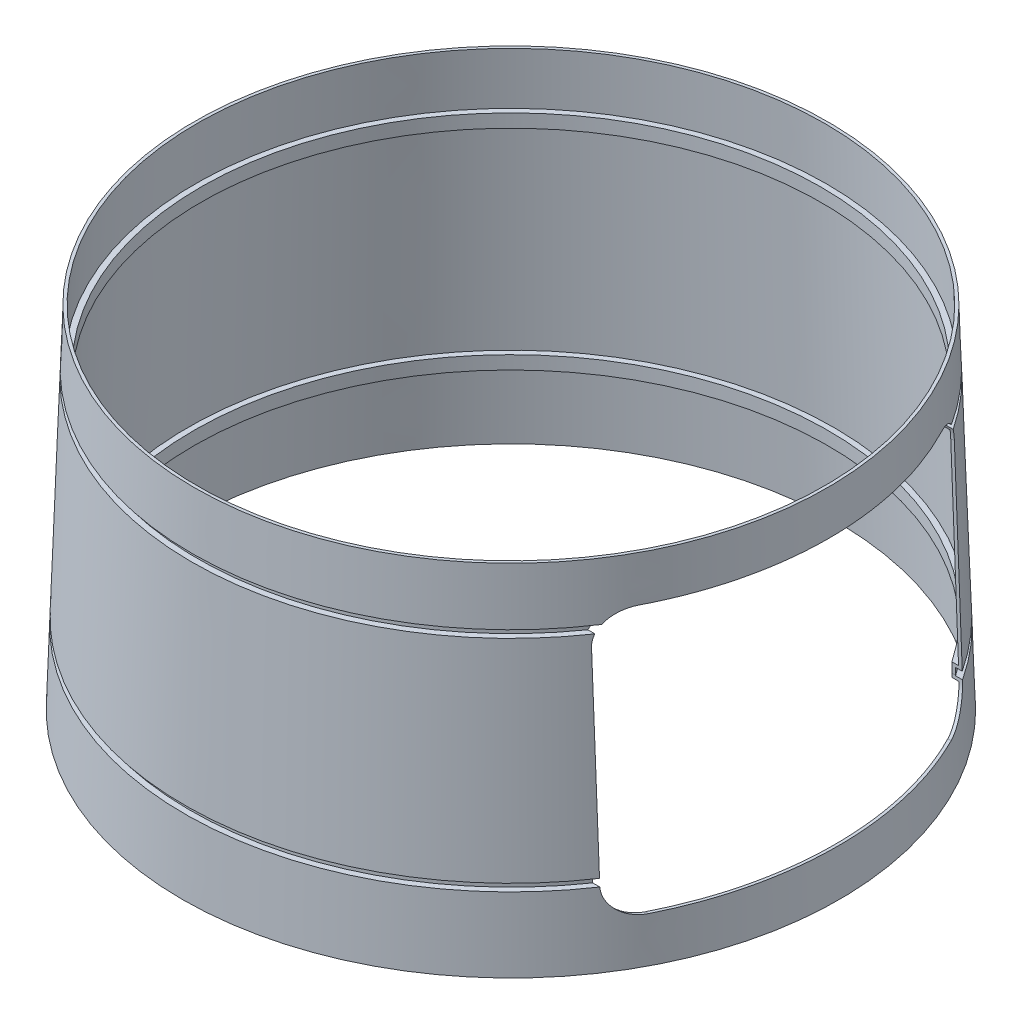
from build123d import *

# Parameters (mm, degrees)
SHELL1_T           = -1
CUT_EXTRUDE1_REACH = 272.851


with BuildPart() as part:
    # Sketch1 → Revolve1 (revolve)
    with BuildSketch(Plane.XY, mode=Mode.PRIVATE) as revolve1_sk:
        Polygon((0, 0), (109.979208013, 0), (109.161205132, 24.375928632), (107.208857797, 24.375928632), (107.208857797, 26.816923755), (109.079290671, 26.816923755), (106.752331603, 96.158718868), (104.799984268, 96.158718868), (104.799984268, 98.599713991), (106.670417142, 98.599713991), (106.0385402, 117.429216448), (0, 117.429216448), align=None)
    revolve(revolve1_sk.sketch.rotate(Axis((0, 117.429216448, 0), (0, -1, 0)), 90), axis=Axis((0, 117.429216448, 0), (0, -1, 0)))

    # Shell1
    shell1_openings = [part.faces().sort_by_distance(p)[0] for p in [
        (0, 0, 0),
        (0, 117.429216448, 0),
    ]]
    offset(amount=SHELL1_T, openings=shell1_openings, kind=Kind.INTERSECTION)

    # Sketch2 → Cut-Extrude1 (cut, up to next)
    with BuildSketch(Plane(origin=(109.855496784, 3.686510337, 0), x_dir=(0, 0, -1), z_dir=(0.9994374116718343, 0.03353893484749475, 0)), mode=Mode.PRIVATE) as cut_extrude1_sk1:
        with BuildLine():
            Line((-50.869164149, 11.565080514), (49.86916415, 11.565080514))
            ThreePointArc((49.86916415, 11.565080514), (56.940231962, 14.494012702), (59.86916415, 21.565080514))
            Line((59.86916415, 21.565080514), (59.86916415, 89.360085428))
            ThreePointArc((59.86916415, 89.360085428), (56.940231962, 96.43115324), (49.86916415, 99.360085428))
            Line((49.86916415, 99.360085428), (-50.869164149, 99.360085428))
            ThreePointArc((-50.869164149, 99.360085428), (-57.940231961, 96.43115324), (-60.869164149, 89.360085428))
            Line((-60.869164149, 89.360085428), (-60.869164149, 21.565080514))
            ThreePointArc((-60.869164149, 21.565080514), (-57.940231961, 14.494012702), (-50.869164149, 11.565080514))
        make_face()
    cut_extrude1_tool1 = extrude(cut_extrude1_sk1.sketch, amount=-CUT_EXTRUDE1_REACH, mode=Mode.PRIVATE) & part.part
    add(cut_extrude1_tool1.solids().sort_by_distance((107.995341, 59.117891, 0.5))[0], mode=Mode.SUBTRACT)


solid = part.part
